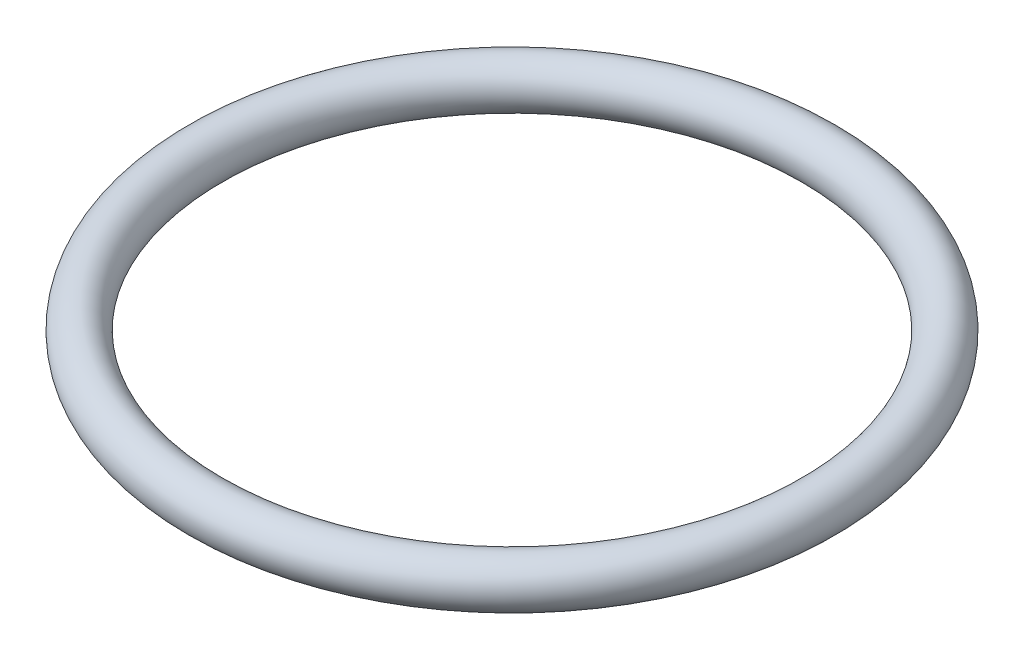
from build123d import *

# Parameters (mm, degrees)
SWEEP1_PROFILE_R = 2


with BuildPart() as part:
    # Sweep1: sweep along a path in Sketch1
    with BuildLine(Plane(origin=(0, 0, 0), x_dir=(1, 0, 0), z_dir=(0, 1, 0))) as sweep1_path:
        CenterArc((0, 0), 26.125, 0, 360)
    # Sweep1 profile (on start of the path) → Sweep1 (sweep)
    with BuildSketch(Plane(origin=(26.125, 0, 0), x_dir=(-1, 0, 0), z_dir=(0, 0, -1))):
        Circle(SWEEP1_PROFILE_R)
    sweep(path=sweep1_path.line)


solid = part.part
